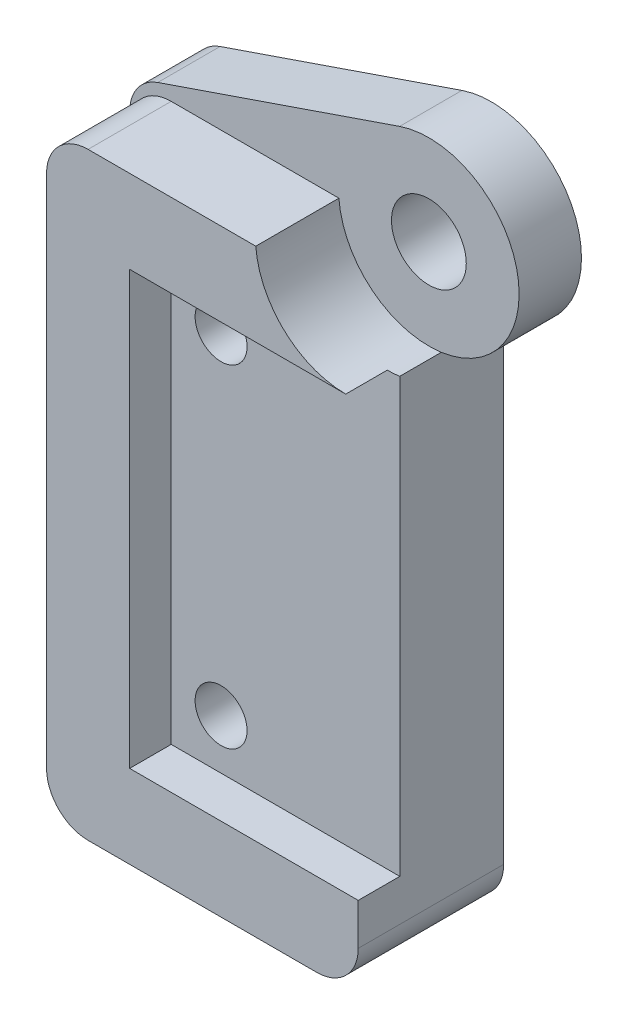
from build123d import *

# Parameters (mm, degrees)
SKETCH1_R           = 1.8
SKETCH1_R_2         = 2.3
BOSS_EXTRUDE1_DEPTH = 3
BOSS_EXTRUDE2_START = 3
SKETCH1_4_R         = 1.25
BOSS_EXTRUDE2_DEPTH = 2
BOSS_EXTRUDE3_START = 5
BOSS_EXTRUDE3_DEPTH = 2
FILLET1_R           = 2
FILLET2_R           = 2


with BuildPart() as part:
    # Sketch1 → Boss-Extrude1 (new body)
    with BuildSketch(Plane.XY):
        with BuildLine():
            Line((-44.4, 14.4), (-44.4, -14.4))
            Line((-44.4, -14.4), (-29.4, -14.4))
            Line((-29.4, -14.4), (-29.4, 10.441638902))
            ThreePointArc((-29.4, 10.441638902), (-25.775066243, 15.752493555), (-31.408334135, 18.852753985))
            Line((-31.408334135, 18.852753985), (-44.4, 14.4))
        make_face()
        with Locations((-30, 14.7437)):
            Circle(SKETCH1_R, mode=Mode.SUBTRACT)
        with Locations((-38, 8)):
            Circle(SKETCH1_R_2, mode=Mode.SUBTRACT)
        with Locations((-38, -8)):
            Circle(SKETCH1_R_2, mode=Mode.SUBTRACT)
    extrude(amount=BOSS_EXTRUDE1_DEPTH)

    # Sketch1_4 → Boss-Extrude2 (add)
    with BuildSketch(Plane.XY.offset(BOSS_EXTRUDE2_START)):
        with BuildLine():
            Line((-29.4, -14.4), (-29.4, 10.441638902))
            ThreePointArc((-29.4, 10.441638902), (-32.719472632, 11.356636627), (-34.330080831, 14.4))
            Line((-34.330080831, 14.4), (-44.4, 14.4))
            Line((-44.4, 14.4), (-44.4, -14.4))
            Line((-44.4, -14.4), (-29.4, -14.4))
        make_face()
        with Locations((-38, -8)):
            Circle(SKETCH1_4_R, mode=Mode.SUBTRACT)
        with Locations((-38, 8)):
            Circle(SKETCH1_4_R, mode=Mode.SUBTRACT)
    extrude(amount=BOSS_EXTRUDE2_DEPTH)

    # Sketch1_5 → Boss-Extrude3 (add)
    with BuildSketch(Plane.XY.offset(BOSS_EXTRUDE3_START)):
        with BuildLine():
            Line((-29.4, -14.4), (-29.4, -10.4))
            Line((-29.4, -10.4), (-40.4, -10.4))
            Line((-40.4, -10.4), (-40.4, 10.4))
            Line((-40.4, 10.4), (-30, 10.4))
            ThreePointArc((-30, 10.4), (-32.947439567, 11.553037108), (-34.330080831, 14.4))
            Line((-34.330080831, 14.4), (-44.4, 14.4))
            Line((-44.4, 14.4), (-44.4, -14.4))
            Line((-44.4, -14.4), (-29.4, -14.4))
        make_face()
    extrude(amount=BOSS_EXTRUDE3_DEPTH)

    # Fillet1
    fillet1_edges = [part.edges().sort_by_distance(p)[0] for p in [
        (-29.4, -14.4, 3.5),
        (-44.4, -14.4, 3.5),
        (-44.4, 14.4, 5),
    ]]
    fillet(fillet1_edges, radius=FILLET1_R)

    # Fillet2
    fillet2_edges = [part.edges().sort_by_distance(p)[0] for p in [
        (-44.4, 14.4, 1.5),
    ]]
    fillet(fillet2_edges, radius=FILLET2_R)


solid = part.part
